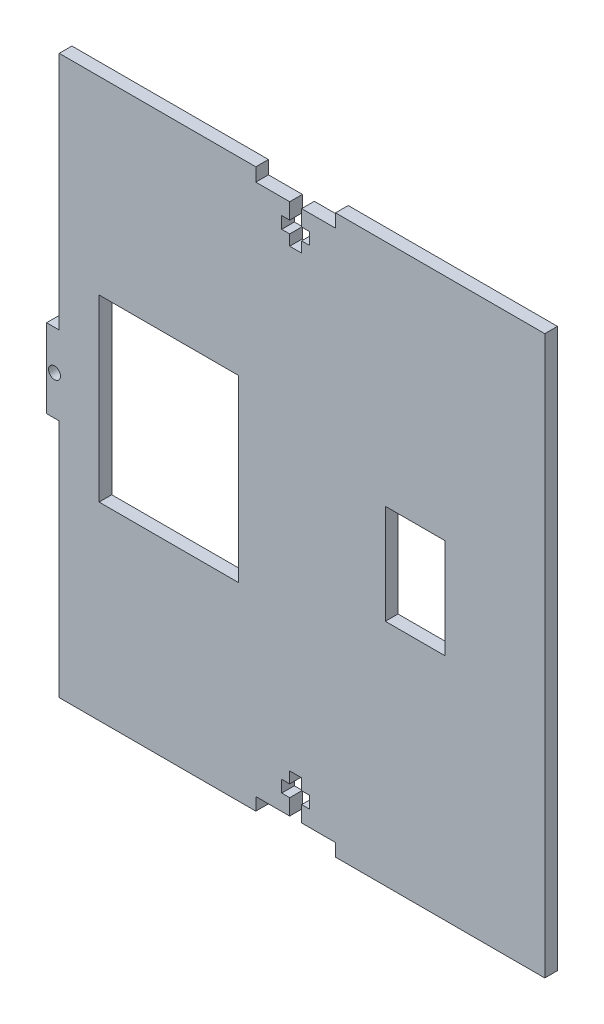
from build123d import *

# Parameters (mm, degrees)
SKETCH1_W           = 125
SKETCH1_H           = 140
BOSS_EXTRUDE1_DEPTH = 3.18
SKETCH2_R           = 1.5
SKETCH2_W           = 3.18
SKETCH2_H           = 60.125
SKETCH2_W_2         = 21.82
SKETCH2_H_2         = 64.054089404
SKETCH2_H_3         = 65
CUT_EXTRUDE1_DEPTH  = 4.18
SKETCH12_W          = 35
SKETCH12_H          = 45
CUT_EXTRUDE6_DEPTH  = 4.18
SKETCH13_W          = 15
SKETCH13_H          = 25
CUT_EXTRUDE7_DEPTH  = 4.18
CUT_EXTRUDE11_DEPTH = 10


with BuildPart() as part:
    # Sketch1 → Boss-Extrude1 (new body)
    with BuildSketch(Plane.XY):
        Rectangle(SKETCH1_W, SKETCH1_H)
    extrude(amount=BOSS_EXTRUDE1_DEPTH)

    # Sketch2 → Cut-Extrude1 (cut, through all)
    with BuildSketch(Plane.XY.offset(3.18)):
        with Locations((-60.5, 0)):
            Circle(SKETCH2_R)
        with Locations((85.5, 0)):
            Circle(SKETCH2_R)
        with Locations((-60.91, 39.9375)):
            Rectangle(SKETCH2_W, SKETCH2_H)
        with Locations((-60.91, -39.9375)):
            Rectangle(SKETCH2_W, SKETCH2_H)
        with Locations((73.41, -41.902044702)):
            Rectangle(SKETCH2_W_2, SKETCH2_H_2)
        with Locations((73.41, 42.625)):
            Rectangle(SKETCH2_W_2, SKETCH2_H_3)
        Polygon((1.5, -66.82), (10, -66.82), (10, -70), (-10, -70), (-10, -66.82), (-1.5, -66.82), (-1.5, -62.82), (-3.5, -62.82), (-3.5, -59.82), (-1.5, -59.82), (-1.5, -57), (1.5, -57), (1.5, -59.82), (3.5, -59.82), (3.5, -62.82), (1.5, -62.82), align=None)
    extrude(amount=-CUT_EXTRUDE1_DEPTH, mode=Mode.SUBTRACT)

    # Sketch12 → Cut-Extrude6 (cut, through all)
    with BuildSketch(Plane(origin=(0, 0, 0), x_dir=(-1, 0, 0), z_dir=(0, 0, -1))):
        with Locations((31.82, 0)):
            Rectangle(SKETCH12_W, SKETCH12_H)
    extrude(amount=-CUT_EXTRUDE6_DEPTH, mode=Mode.SUBTRACT)

    # Sketch13 → Cut-Extrude7 (cut, through all)
    with BuildSketch(Plane(origin=(0, 0, 0), x_dir=(-1, 0, 0), z_dir=(0, 0, -1))):
        with Locations((-30, 0)):
            Rectangle(SKETCH13_W, SKETCH13_H)
    extrude(amount=-CUT_EXTRUDE7_DEPTH, mode=Mode.SUBTRACT)

    # Sketch11 → Cut-Extrude11 (cut)
    with BuildSketch(Plane(origin=(0, 0, 0), x_dir=(-1, 0, 0), z_dir=(0, 0, -1))):
        Polygon((-10, 66.67), (-1.5, 66.67), (-1.5, 62.67), (-3.5, 62.67), (-3.5, 59.67), (-1.5, 59.67), (-1.5, 57), (1.5, 57), (1.5, 59.67), (3.5, 59.67), (3.5, 62.67), (1.5, 62.67), (1.5, 66.67), (10, 66.67), (10, 70), (-10, 70), align=None)
    extrude(amount=-CUT_EXTRUDE11_DEPTH, mode=Mode.SUBTRACT)


solid = part.part
